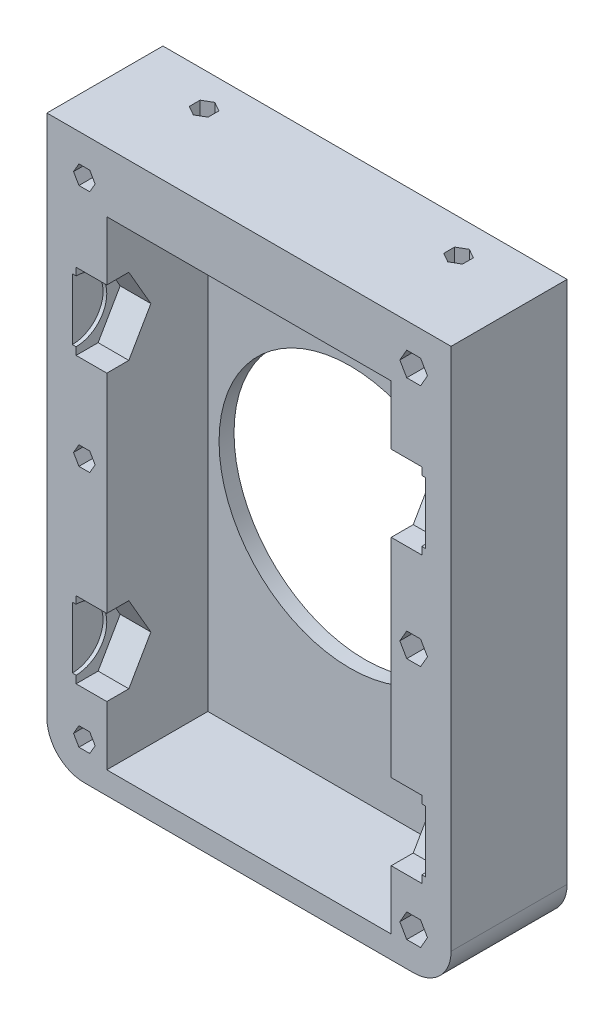
from build123d import *

# Parameters (mm, degrees)
SKETCH1_W           = 54
SKETCH1_H           = 75
SKETCH1_W_2         = 38
SKETCH1_H_2         = 64
BOSS_EXTRUDE1_DEPTH = 27
CUT_EXTRUDE1_DEPTH  = 4.1
SKETCH5_R           = 4.1
CUT_EXTRUDE2_DEPTH  = 0.5
CUT_EXTRUDE3_DEPTH  = 4.1
SKETCH7_R           = 4.1
CUT_EXTRUDE4_DEPTH  = 0.5
SKETCH8_W           = 54
SKETCH8_H           = 75
BOSS_EXTRUDE2_DEPTH = 2
SKETCH9_W           = 54
SKETCH9_H           = 75
BOSS_EXTRUDE3_DEPTH = 2
SKETCH10_W          = 54
SKETCH10_H          = 75
CUT_EXTRUDE5_DEPTH  = 15.5
SKETCH11_R          = 17.5
CUT_EXTRUDE6_DEPTH  = 3
CUT_EXTRUDE7_DEPTH  = 16.5
SKETCH14_W          = 38
SKETCH14_H          = 5
BOSS_EXTRUDE4_DEPTH = 4
CUT_EXTRUDE8_REACH  = 77
FILLET1_R           = 5


with BuildPart() as part:
    # Sketch1 → Boss-Extrude1 (new body)
    with BuildSketch(Plane.XY):
        with Locations((27, 37.5)):
            Rectangle(SKETCH1_W, SKETCH1_H)
        with Locations((27, 35)):
            Rectangle(SKETCH1_W_2, SKETCH1_H_2, mode=Mode.SUBTRACT)
    extrude(amount=BOSS_EXTRUDE1_DEPTH)

    # Sketch2 → Cut-Extrude1 (cut)
    with BuildSketch(Plane.ZY.offset(-46)):
        Polygon((19.388972746, 54), (16.444486373, 59.1), (10.555513627, 59.1), (7.611027254, 54), (10.555513627, 48.9), (16.444486373, 48.9), align=None)
        Polygon((19.388972746, 16), (16.444486373, 21.1), (10.555513627, 21.1), (7.611027254, 16), (10.555513627, 10.9), (16.444486373, 10.9), align=None)
    extrude(amount=-CUT_EXTRUDE1_DEPTH, mode=Mode.SUBTRACT)

    # Sketch5 → Cut-Extrude2 (cut)
    with BuildSketch(Plane.ZY.offset(-50.1)):
        with Locations((13.5, 54)):
            Circle(SKETCH5_R)
        with Locations((13.5, 16)):
            Circle(SKETCH5_R)
    extrude(amount=-CUT_EXTRUDE2_DEPTH, mode=Mode.SUBTRACT)

    # Sketch6 → Cut-Extrude3 (cut)
    with BuildSketch(Plane(origin=(8, 0, 0), x_dir=(0, 0, -1), z_dir=(1, 0, 0))):
        Polygon((-7.611027254, 54), (-10.555513627, 59.1), (-16.444486373, 59.1), (-19.388972746, 54), (-16.444486373, 48.9), (-10.555513627, 48.9), align=None)
        Polygon((-7.611027254, 16), (-10.555513627, 21.1), (-16.444486373, 21.1), (-19.388972746, 16), (-16.444486373, 10.9), (-10.555513627, 10.9), align=None)
    extrude(amount=-CUT_EXTRUDE3_DEPTH, mode=Mode.SUBTRACT)

    # Sketch7 → Cut-Extrude4 (cut)
    with BuildSketch(Plane(origin=(3.9, 0, 0), x_dir=(0, 0, -1), z_dir=(1, 0, 0))):
        with Locations((-13.5, 54)):
            Circle(SKETCH7_R)
        with Locations((-13.5, 16)):
            Circle(SKETCH7_R)
    extrude(amount=-CUT_EXTRUDE4_DEPTH, mode=Mode.SUBTRACT)

    # Sketch8 → Boss-Extrude2 (add)
    with BuildSketch(Plane.XY.offset(27)):
        with Locations((27, 37.5)):
            Rectangle(SKETCH8_W, SKETCH8_H)
    extrude(amount=BOSS_EXTRUDE2_DEPTH)

    # Sketch9 → Boss-Extrude3 (add)
    with BuildSketch(Plane(origin=(0, 0, 0), x_dir=(-1, 0, 0), z_dir=(0, 0, -1))):
        with Locations((-27, 37.5)):
            Rectangle(SKETCH9_W, SKETCH9_H)
    extrude(amount=BOSS_EXTRUDE3_DEPTH)

    # Sketch10 → Cut-Extrude5 (cut)
    with BuildSketch(Plane.XY.offset(29)):
        with Locations((27, 37.5)):
            Rectangle(SKETCH10_W, SKETCH10_H)
    extrude(amount=-CUT_EXTRUDE5_DEPTH, mode=Mode.SUBTRACT)

    # Sketch11 → Cut-Extrude6 (cut, through all)
    with BuildSketch(Plane.XY):
        with Locations((27, 35)):
            Circle(SKETCH11_R)
    extrude(amount=-CUT_EXTRUDE6_DEPTH, mode=Mode.SUBTRACT)

    # Sketch12 → Cut-Extrude7 (cut, through all)
    with BuildSketch(Plane.XY.offset(13.5)):
        Polygon((6.443375673, 70), (5.721687836, 71.25), (4.278312164, 71.25), (3.556624327, 70), (4.278312164, 68.75), (5.721687836, 68.75), align=None)
        Polygon((50.847520861, 70), (49.923760431, 71.6), (48.076239569, 71.6), (47.152479139, 70), (48.076239569, 68.4), (49.923760431, 68.4), align=None)
        Polygon((6.443375673, 5), (5.721687836, 6.25), (4.278312164, 6.25), (3.556624327, 5), (4.278312164, 3.75), (5.721687836, 3.75), align=None)
        Polygon((50.847520861, 5), (49.923760431, 6.6), (48.076239569, 6.6), (47.152479139, 5), (48.076239569, 3.4), (49.923760431, 3.4), align=None)
        Polygon((50.847520861, 37.5), (49.923760431, 39.1), (48.076239569, 39.1), (47.152479139, 37.5), (48.076239569, 35.9), (49.923760431, 35.9), align=None)
        Polygon((6.443375673, 37.5), (5.721687836, 38.75), (4.278312164, 38.75), (3.556624327, 37.5), (4.278312164, 36.25), (5.721687836, 36.25), align=None)
    extrude(amount=-CUT_EXTRUDE7_DEPTH, mode=Mode.SUBTRACT)

    # Sketch14 → Boss-Extrude4 (add)
    with BuildSketch(Plane.XZ.offset(-67)):
        with Locations((27, 2.5)):
            Rectangle(SKETCH14_W, SKETCH14_H)
    extrude(amount=BOSS_EXTRUDE4_DEPTH)

    # Sketch13 → Cut-Extrude8 (cut, up to next)
    with BuildSketch(Plane(origin=(0, 75, 0), x_dir=(1, 0, 0), z_dir=(0, 1, 0)), mode=Mode.PRIVATE) as cut_extrude8_sk1:
        Polygon((44, -1.056624327), (42.75, -1.778312164), (42.75, -3.221687836), (44, -3.943375673), (45.25, -3.221687836), (45.25, -1.778312164), align=None)
    cut_extrude8_tool1 = extrude(cut_extrude8_sk1.sketch, amount=-CUT_EXTRUDE8_REACH, mode=Mode.PRIVATE) & part.part
    add(cut_extrude8_tool1.solids().sort_by_distance((44, 75, 2.5))[0], mode=Mode.SUBTRACT)
    # Sketch13 → Cut-Extrude8 (cut, up to next)
    with BuildSketch(Plane(origin=(0, 75, 0), x_dir=(1, 0, 0), z_dir=(0, 1, 0)), mode=Mode.PRIVATE) as cut_extrude8_sk2:
        Polygon((10, -1.056624327), (8.75, -1.778312164), (8.75, -3.221687836), (10, -3.943375673), (11.25, -3.221687836), (11.25, -1.778312164), align=None)
    cut_extrude8_tool2 = extrude(cut_extrude8_sk2.sketch, amount=-CUT_EXTRUDE8_REACH, mode=Mode.PRIVATE) & part.part
    add(cut_extrude8_tool2.solids().sort_by_distance((10, 75, 2.5))[0], mode=Mode.SUBTRACT)

    # Fillet1
    fillet1_edges = [part.edges().sort_by_distance(p)[0] for p in [
        (0, 0, 5.75),
        (54, 0, 5.75),
    ]]
    fillet(fillet1_edges, radius=FILLET1_R)


solid = part.part
